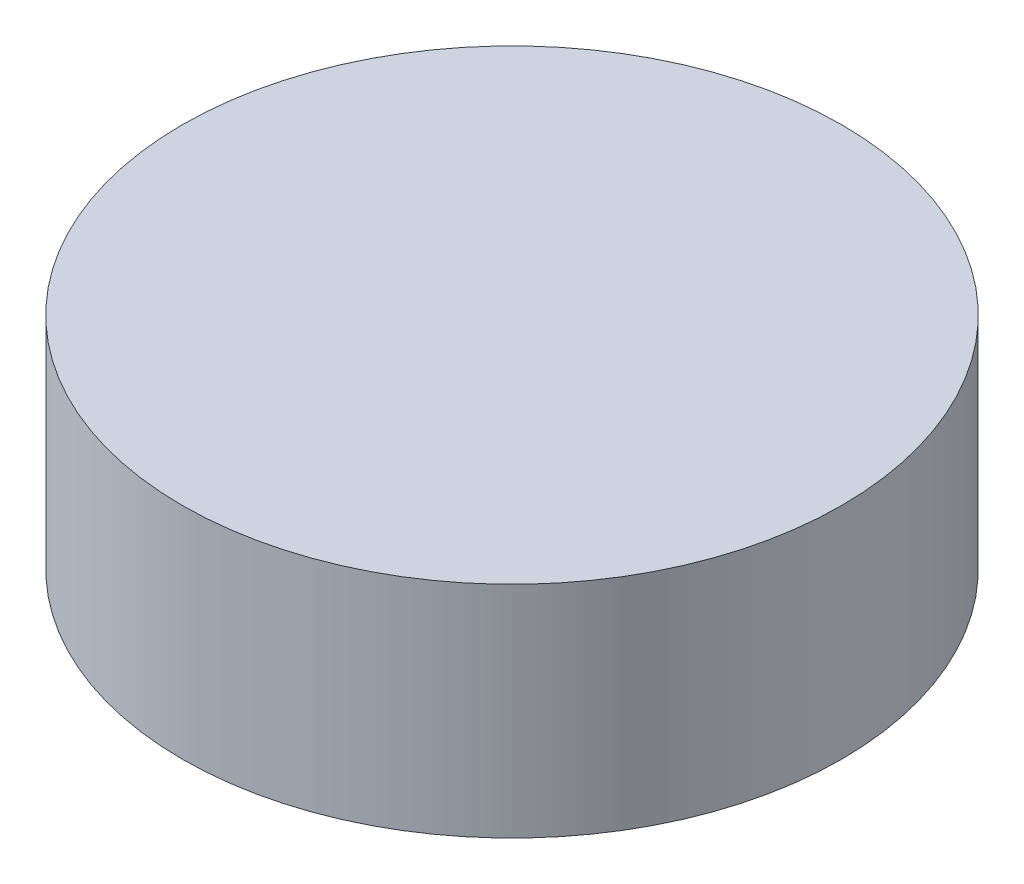
from build123d import *

# Parameters (mm, degrees)
SKETCH1_R           = 15
BOSS_EXTRUDE1_DEPTH = 10
SKETCH2_R           = 4.5
BOSS_EXTRUDE2_DEPTH = 3


with BuildPart() as part:
    # Sketch1 → Boss-Extrude1 (new body)
    with BuildSketch(Plane(origin=(0, 0, 0), x_dir=(1, 0, 0), z_dir=(0, 1, 0))):
        Circle(SKETCH1_R)
    extrude(amount=BOSS_EXTRUDE1_DEPTH)

    # Sketch2 → Boss-Extrude2 (add)
    with BuildSketch(Plane.XZ):
        Circle(SKETCH2_R)
    extrude(amount=BOSS_EXTRUDE2_DEPTH)


solid = part.part
